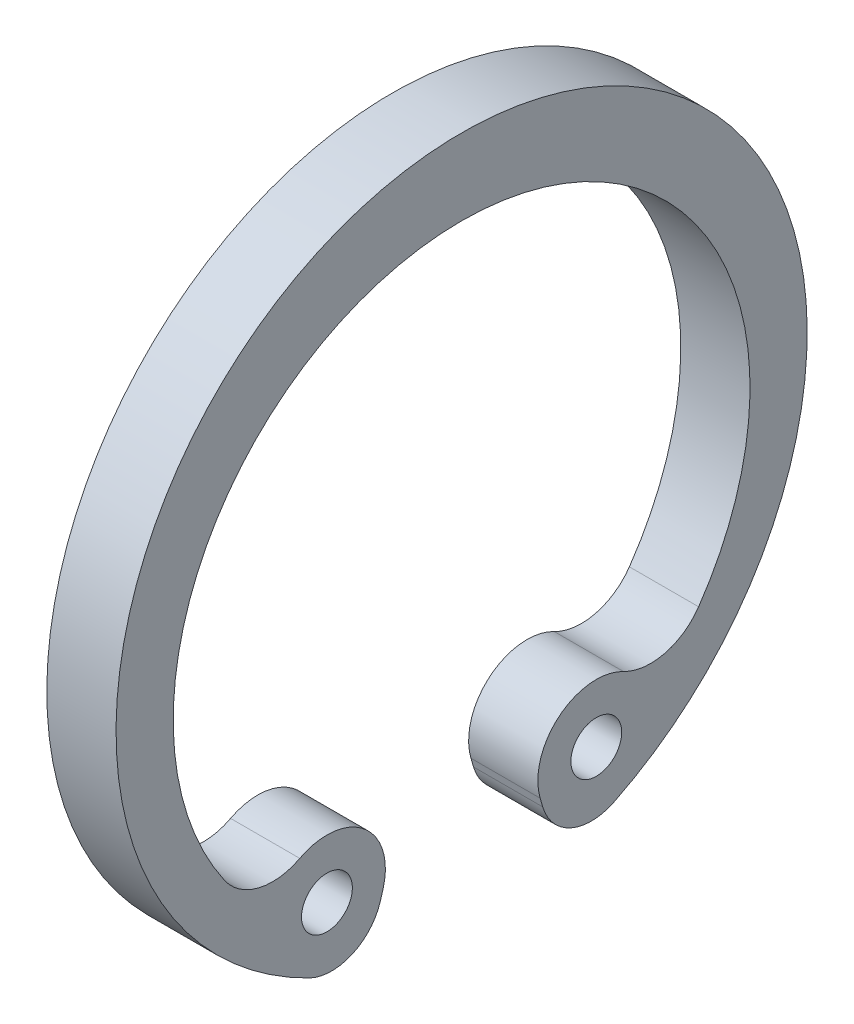
from build123d import *

# Parameters (mm, degrees)
SKETCH1_R           = 0.440528634
BOSS_EXTRUDE1_DEPTH = 1.2


with BuildPart() as part:
    # Sketch1 → Boss-Extrude1 (new body)
    with BuildSketch(Plane(origin=(0.6, 0, 0), x_dir=(0, 0, -1), z_dir=(1, 0, 0))):
        with BuildLine():
            Line((-1.406616674, -4.833075449), (-1.361950738, -4.679605182))
            ThreePointArc((-1.361950738, -4.679605182), (-1.693445711, -3.612076228), (-2.805550353, -3.499247827))
            ThreePointArc((-2.805550353, -3.499247827), (-3.517808728, -3.586040603), (-4.108949504, -3.179349612))
            ThreePointArc((-4.108949504, -3.179349612), (0, 4.669603524), (4.108949504, -3.179349612))
            ThreePointArc((4.108949504, -3.179349612), (3.517808728, -3.586040603), (2.805550353, -3.499247827))
            ThreePointArc((2.805550353, -3.499247827), (1.693445711, -3.612076228), (1.361950738, -4.679605182))
            Line((1.361950738, -4.679605182), (1.406616674, -4.833075449))
            ThreePointArc((1.406616674, -4.833075449), (1.89690358, -5.392945454), (2.640948929, -5.377707645))
            ThreePointArc((2.640948929, -5.377707645), (0, 5.991189427), (-2.640948929, -5.377707645))
            ThreePointArc((-2.640948929, -5.377707645), (-1.89690358, -5.392945454), (-1.406616674, -4.833075449))
        make_face()
        with Locations((-2.334801762, -4.396466943)):
            Circle(SKETCH1_R, mode=Mode.SUBTRACT)
        with Locations((2.334801762, -4.396466943)):
            Circle(SKETCH1_R, mode=Mode.SUBTRACT)
    extrude(amount=-BOSS_EXTRUDE1_DEPTH)


solid = part.part
